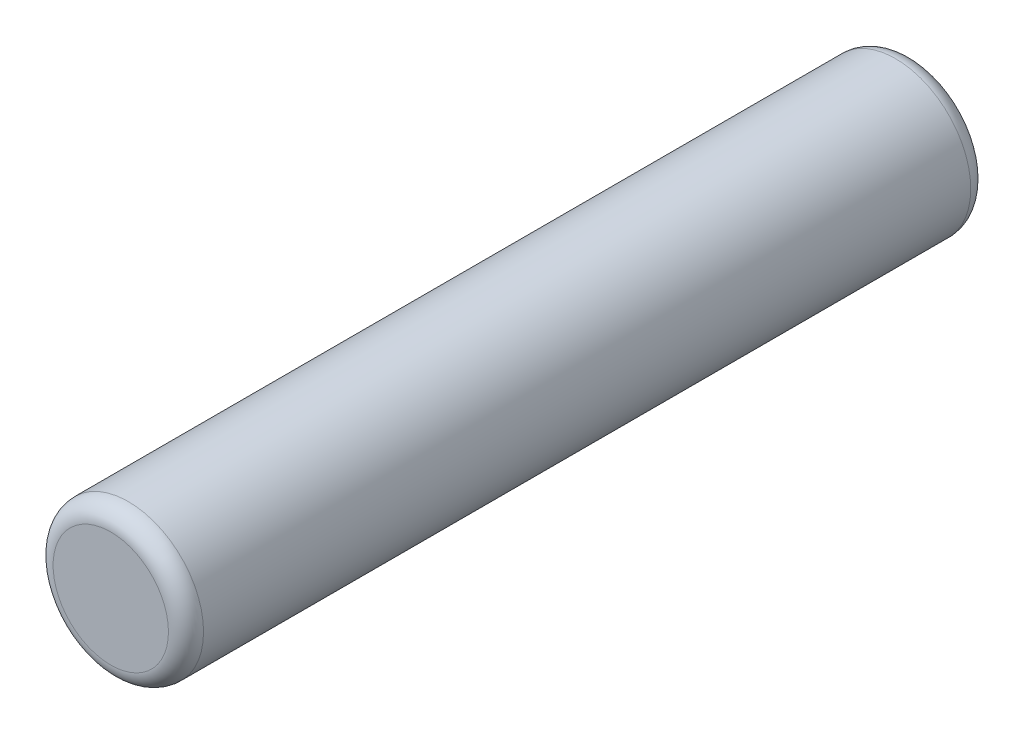
from build123d import *

# Parameters (mm, degrees)
SKETCH1_R           = 1.5
BOSS_EXTRUDE1_DEPTH = 8
FILLET1_R           = 0.35


with BuildPart() as part:
    # Sketch1 → Boss-Extrude1 (new body, symmetric)
    with BuildSketch(Plane.XY):
        Circle(SKETCH1_R)
    extrude(amount=BOSS_EXTRUDE1_DEPTH, both=True)

    # Fillet1
    fillet1_edges = [part.edges().sort_by_distance(p)[0] for p in [
        (-1.5, 0, -8),
        (-1.5, 0, 8),
    ]]
    fillet(fillet1_edges, radius=FILLET1_R)


solid = part.part
